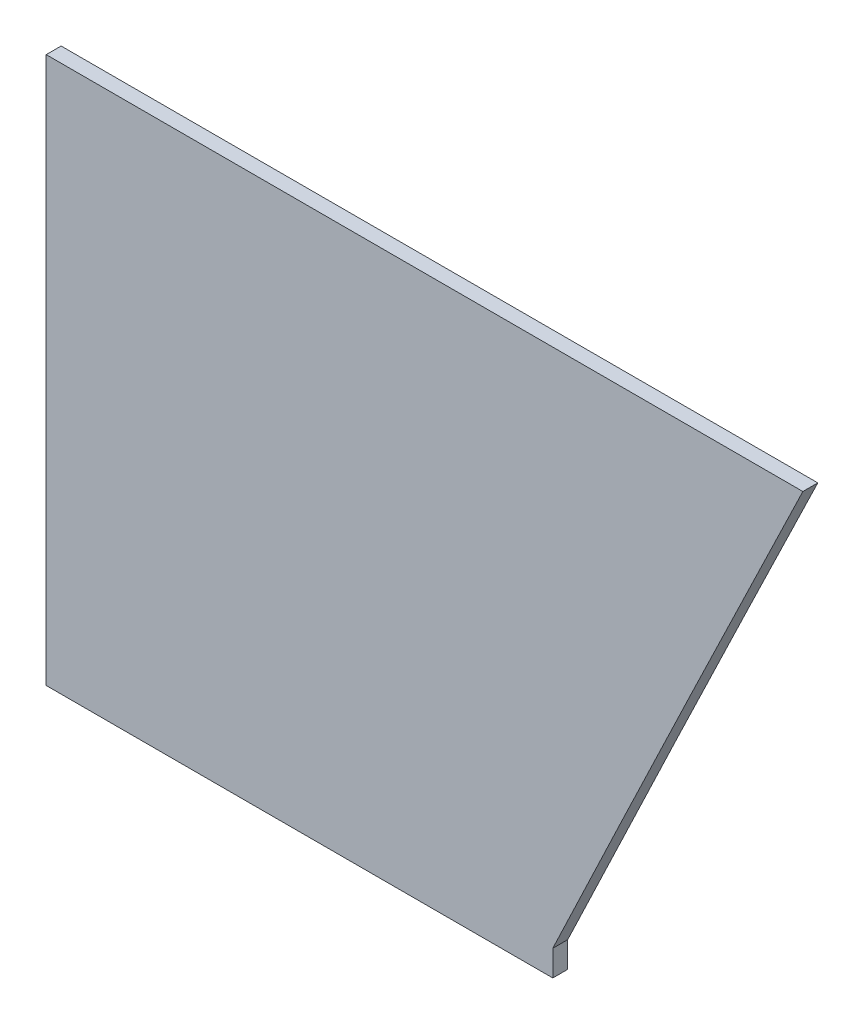
from build123d import *

# Parameters (mm, degrees)
BOSS_EXTRUDE2_DEPTH = 10.16


with BuildPart() as part:
    # Sketch1 → Boss-Extrude2 (new body)
    with BuildSketch(Plane.XY):
        with BuildLine():
            Line((257.548254828, 177.209298992), (-257.548120057, 177.209396927))
            Line((-257.548120057, 177.209396927), (-257.548187443, -177.20933136))
            Line((-257.548187443, -177.20933136), (-257.548187443, -194.73533136))
            Line((-257.548187443, -194.73533136), (87.305464804, -194.73533136))
            Line((87.305464804, -194.73533136), (87.305464804, -177.209396927))
            add(Edge.make_bspline(
                [(87.305464804, -177.209396927), (115.443687234, -118.026720576), (143.693138312, -58.89727283), (200.435070064, 59.245320553), (228.928258607, 118.258075422), (257.548254828, 177.209298992)],
                knots=[0, 0, 0, 0, 0.5, 0.5, 1, 1, 1, 1], degree=3))
        make_face()
    extrude(amount=BOSS_EXTRUDE2_DEPTH)


solid = part.part
